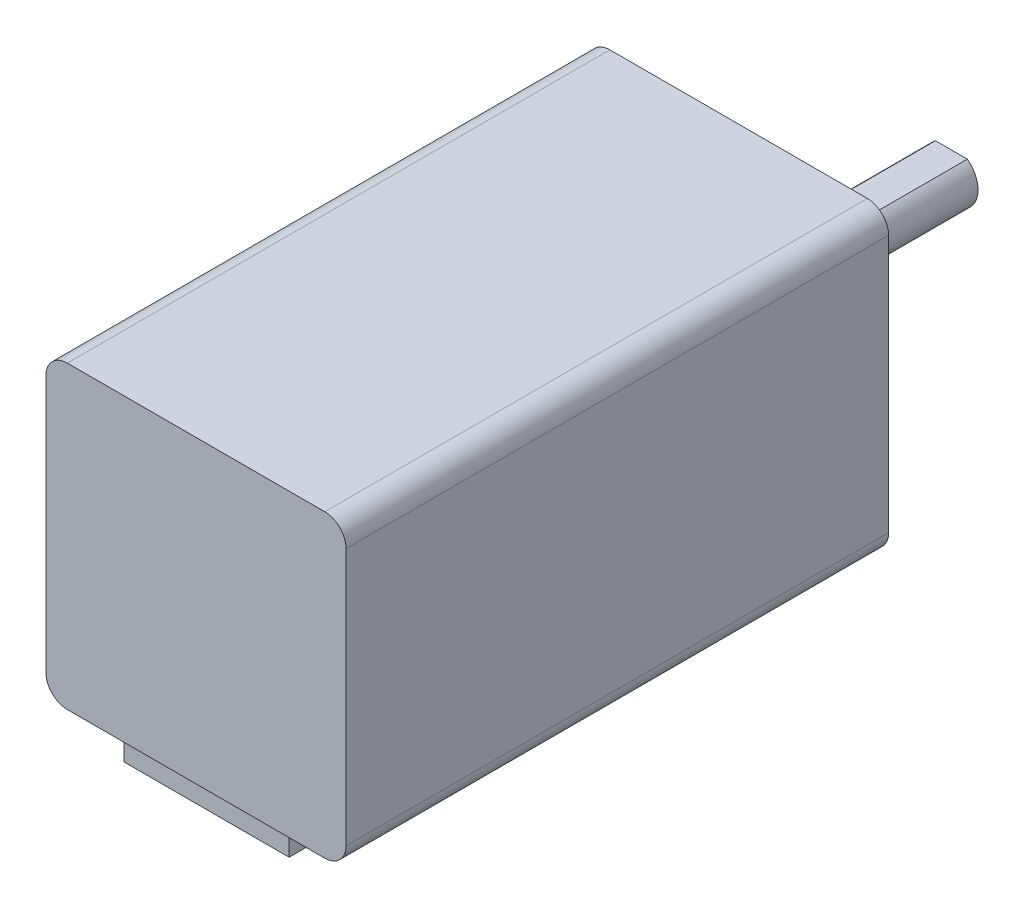
from build123d import *

# Parameters (mm, degrees)
EXTRUDE_2_DEPTH          = 51
HOLE_WIZARD_M2_5_1_D     = 2.05
HOLE_WIZARD_M2_5_1_DEPTH = 4.75
HOLE_WIZARD_M2_5_1_TIP   = 0.615882135
SKETCH_7_R               = 11
SKETCH_7_R_2             = 2.5
EXTRUDE_3_DEPTH          = 2
SKETCH_7_2_R             = 2.5
EXTRUDE_4_DEPTH          = 20
SKETCH_8_W               = 15
SKETCH_8_H               = 0.5
CUT_EXTRUDE_1_DEPTH      = 1.5
SKETCH_9_W               = 15.5
SKETCH_9_H               = 2.6
EXTRUDE_5_DEPTH          = 6


with BuildPart() as part:
    # 草图1 → 凸台-拉伸2 (new body)
    with BuildSketch(Plane.XY):
        with BuildLine():
            ThreePointArc((-14.1, -12.1), (-13.514213562, -13.514213562), (-12.1, -14.1))
            Line((-12.1, -14.1), (12.1, -14.1))
            ThreePointArc((12.1, -14.1), (13.514213562, -13.514213562), (14.1, -12.1))
            Line((14.1, -12.1), (14.1, 12.1))
            ThreePointArc((14.1, 12.1), (13.514213562, 13.514213562), (12.1, 14.1))
            Line((12.1, 14.1), (-12.1, 14.1))
            ThreePointArc((-12.1, 14.1), (-13.514213562, 13.514213562), (-14.1, 12.1))
            Line((-14.1, 12.1), (-14.1, -12.1))
        make_face()
    extrude(amount=EXTRUDE_2_DEPTH)

    # M2.5 螺纹孔1
    with Locations(Plane(origin=(0, 0, 0), x_dir=(-1, 0, 0), z_dir=(0, 0, -1))):
        with Locations((-11.5, 11.5), (11.5, 11.5), (11.5, -11.5), (-11.5, -11.5)):
            Hole(HOLE_WIZARD_M2_5_1_D / 2, depth=HOLE_WIZARD_M2_5_1_DEPTH)
            with Locations((0, 0, -(HOLE_WIZARD_M2_5_1_DEPTH + HOLE_WIZARD_M2_5_1_TIP / 2))):  # 118° drill point
                Cone(0, HOLE_WIZARD_M2_5_1_D / 2, HOLE_WIZARD_M2_5_1_TIP, mode=Mode.SUBTRACT)

    # 草图7 → 凸台-拉伸3 (add)
    with BuildSketch(Plane.XY):
        Circle(SKETCH_7_R)
        Circle(SKETCH_7_R_2, mode=Mode.SUBTRACT)
    extrude(amount=-EXTRUDE_3_DEPTH)

    # 草图7<2> → 凸台-拉伸4 (add)
    with BuildSketch(Plane.XY):
        Circle(SKETCH_7_2_R)
    extrude(amount=-EXTRUDE_4_DEPTH)

    # 草图8 → 切除-拉伸1 (cut, symmetric)
    with BuildSketch(Plane(origin=(0, 0, 0), x_dir=(0, 0, -1), z_dir=(1, 0, 0))):
        with Locations((12.5, 2.25)):
            Rectangle(SKETCH_8_W, SKETCH_8_H)
    extrude(amount=CUT_EXTRUDE_1_DEPTH, both=True, mode=Mode.SUBTRACT)

    # 草图9 → 凸台-拉伸5 (add)
    with BuildSketch(Plane.XY.offset(44)):
        with Locations((0, -15.4)):
            Rectangle(SKETCH_9_W, SKETCH_9_H)
    extrude(amount=EXTRUDE_5_DEPTH)


solid = part.part
